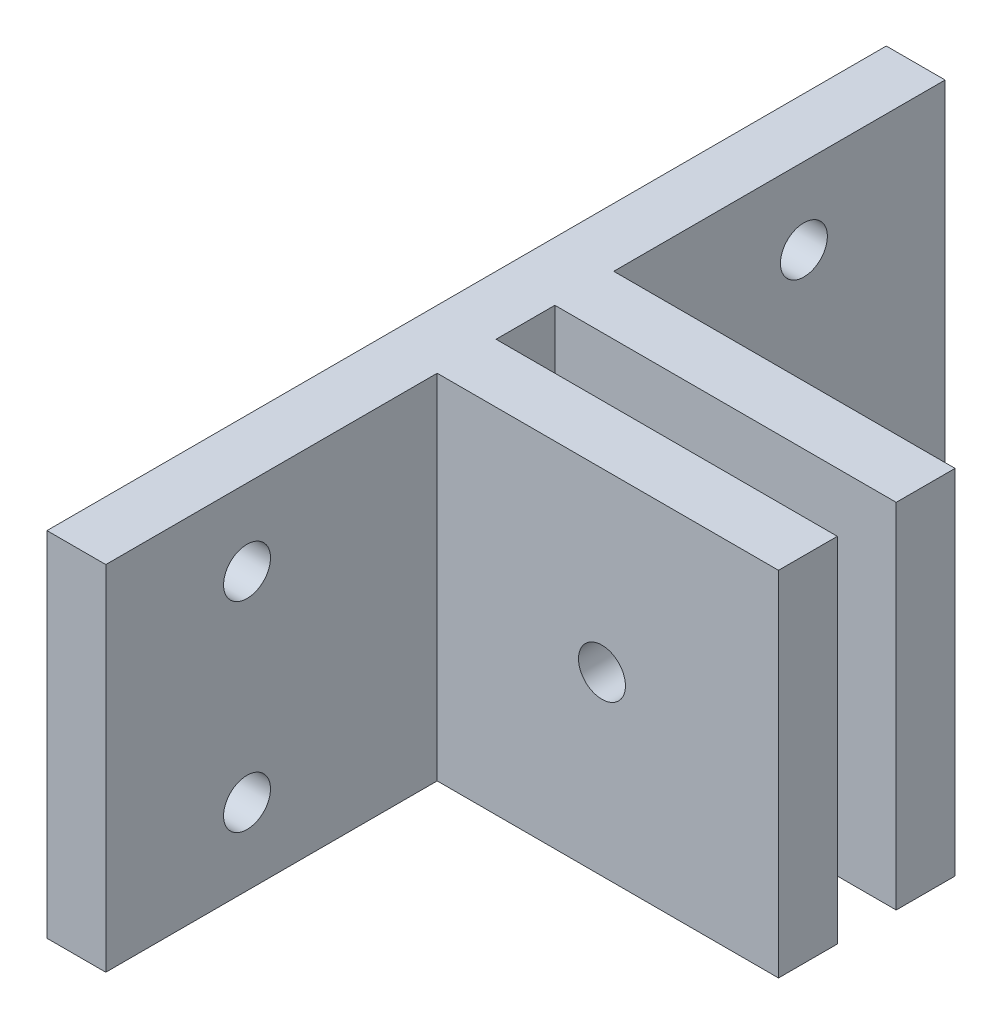
from build123d import *

# Parameters (mm, degrees)
BOSS_EXTRUDE1_DEPTH     = 19.05
SKETCH2_R               = 1.26619
CUT_EXTRUDE1_DEPTH      = 18.879441165
CUT_EXTRUDE1_DEPTH_BACK = 28.404441165
SKETCH3_R               = 1.26619
CUT_EXTRUDE2_DEPTH      = 4.175


with BuildPart() as part:
    # Sketch1 → Boss-Extrude1 (new body)
    with BuildSketch(Plane(origin=(0, 0, 0), x_dir=(1, 0, 0), z_dir=(0, 1, 0))):
        Polygon((0, -22.641941165), (0, 22.641941165), (3.175, 22.641941165), (3.175, 4.7625), (21.59, 4.7625), (21.59, 1.5875), (3.175, 1.5875), (3.175, -1.5875), (21.59, -1.5875), (21.59, -4.7625), (3.175, -4.7625), (3.175, -22.641941165), align=None)
    extrude(amount=BOSS_EXTRUDE1_DEPTH)

    # Sketch2 → Cut-Extrude1 (cut, two sides)
    with BuildSketch(Plane.XY.offset(4.7625)) as cut_extrude1_sk:
        with Locations((12.065, 9.525)):
            Circle(SKETCH2_R)
    extrude(amount=CUT_EXTRUDE1_DEPTH, mode=Mode.SUBTRACT)
    extrude(cut_extrude1_sk.sketch, amount=-CUT_EXTRUDE1_DEPTH_BACK, mode=Mode.SUBTRACT)

    # Sketch3 → Cut-Extrude2 (cut, through all)
    with BuildSketch(Plane(origin=(3.175, 0, 0), x_dir=(0, 0, -1), z_dir=(1, 0, 0))):
        with Locations((-15.021941165, 14.9225)):
            Circle(SKETCH3_R)
        with Locations((-15.021941165, 4.1275)):
            Circle(SKETCH3_R)
        with Locations((15.021941165, 4.1275)):
            Circle(SKETCH3_R)
        with Locations((15.021941165, 14.9225)):
            Circle(SKETCH3_R)
    extrude(amount=-CUT_EXTRUDE2_DEPTH, mode=Mode.SUBTRACT)


solid = part.part
